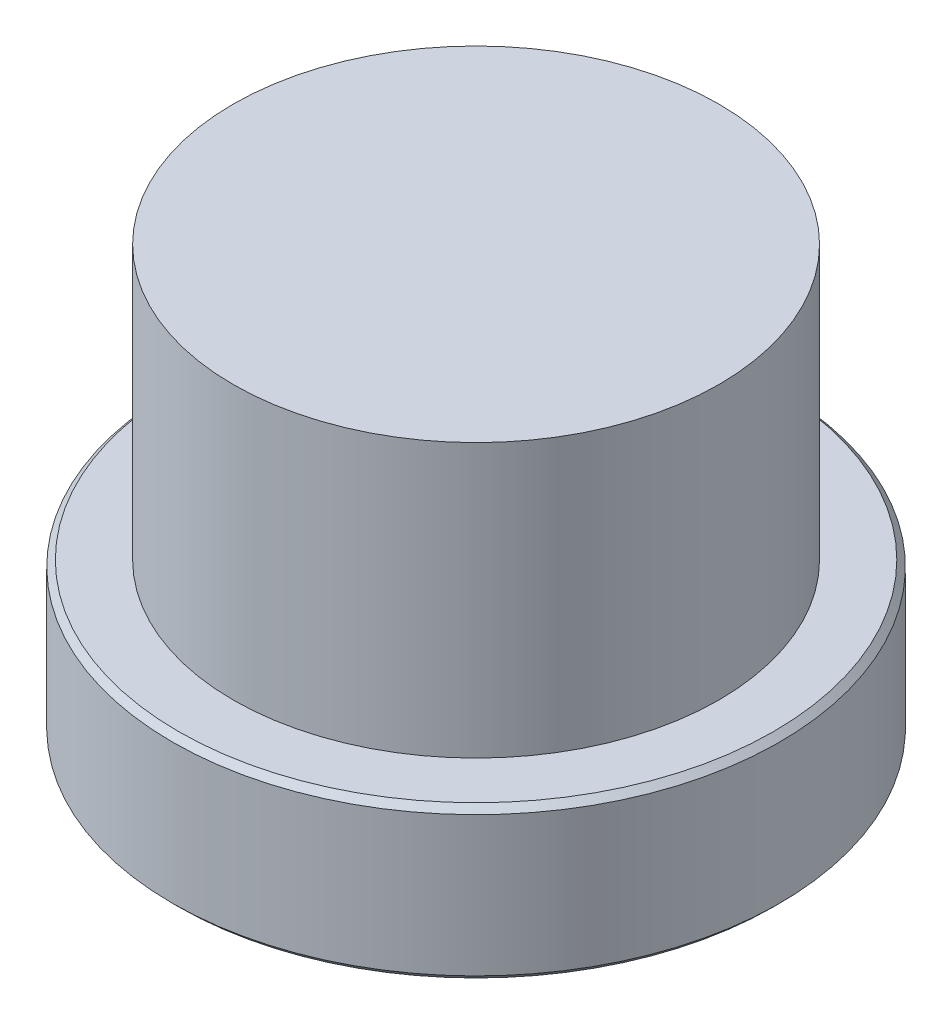
from build123d import *


with BuildPart() as part:
    # Esquisse1 → Révolution1 (revolve)
    with BuildSketch(Plane.XY):
        Polygon((-98, 25), (-100, 23), (-100, -23), (-98, -25), (0, -25), (0, 115), (-80, 115), (-80, 25), align=None)
    revolve(axis=Axis((0, 25, 0), (0, -1, 0)))


solid = part.part
